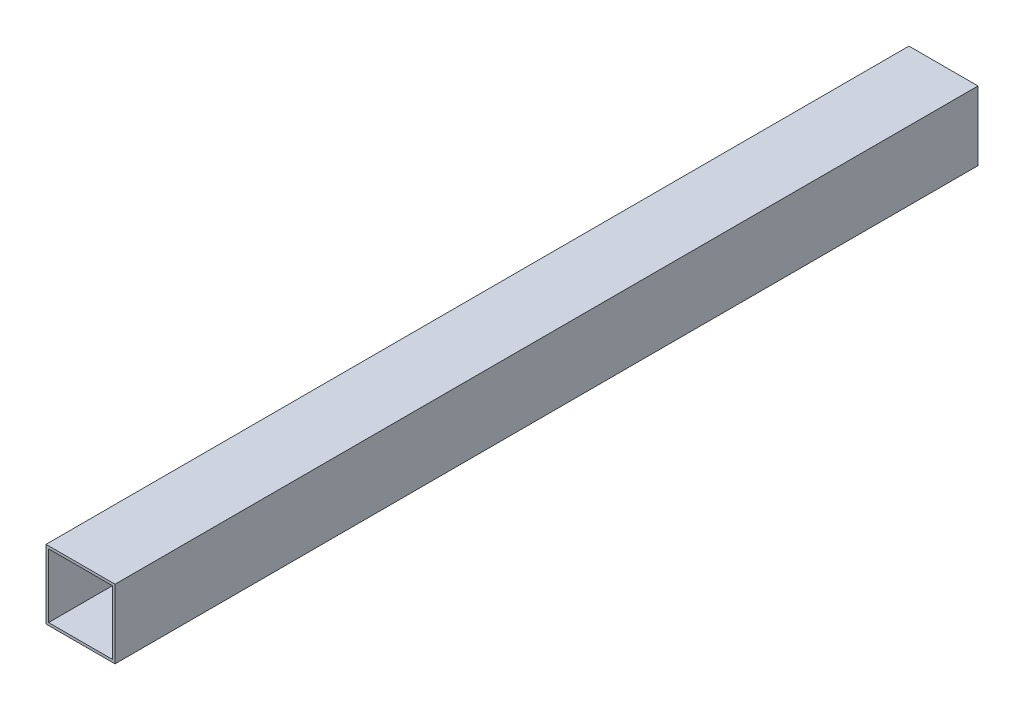
from build123d import *

# Parameters (mm, degrees)
ESQUISSE1_W        = 40
ESQUISSE1_H        = 40
ESQUISSE1_W_2      = 37
ESQUISSE1_H_2      = 37
BOSS_EXTRU_1_DEPTH = 500


with BuildPart() as part:
    # Esquisse1 → Boss.-Extru.1 (new body)
    with BuildSketch(Plane.XY):
        Rectangle(ESQUISSE1_W, ESQUISSE1_H)
        Rectangle(ESQUISSE1_W_2, ESQUISSE1_H_2, mode=Mode.SUBTRACT)
    extrude(amount=BOSS_EXTRU_1_DEPTH)


solid = part.part
